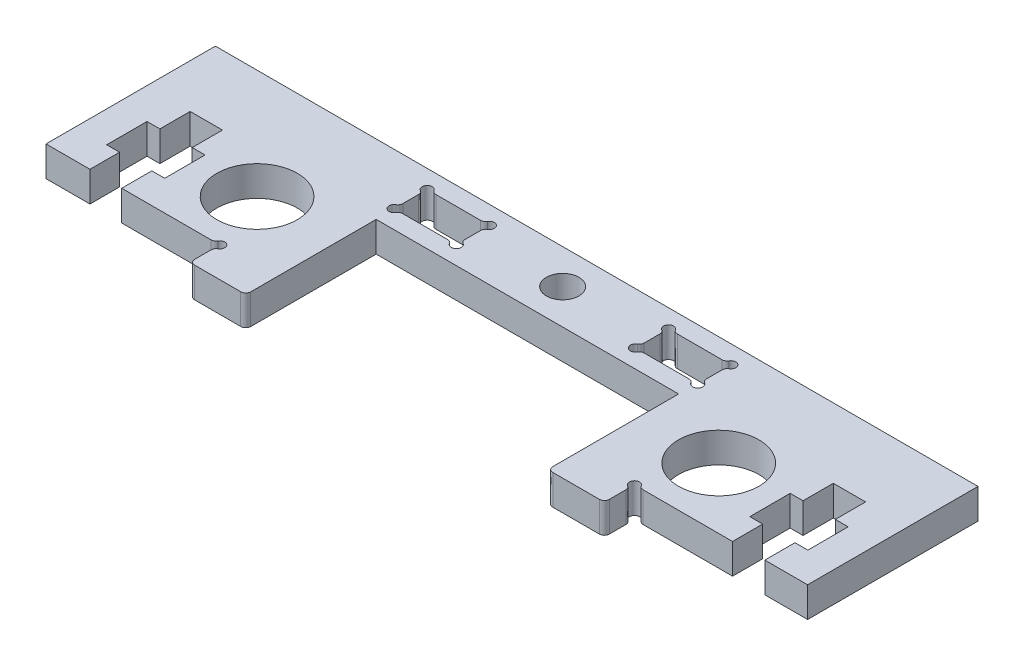
from build123d import *

# Parameters (mm, degrees)
SKETCH1_R           = 4.009255558
SKETCH1_R_2         = 1.619702369
BOSS_EXTRUDE1_DEPTH = 3


with BuildPart() as part:
    # Sketch1 → Boss-Extrude1 (new body)
    with BuildSketch(Plane(origin=(0, 0, 0), x_dir=(1, 0, 0), z_dir=(0, 1, 0))):
        with BuildLine():
            Line((-7.143850408, 18.229298667), (22.987065755, 18.229298667))
            Line((22.987065755, 18.229298667), (22.987065755, 7.324979297))
            Line((22.987065755, 7.324979297), (22.987065755, 5.690951323))
            ThreePointArc((22.987065755, 5.690951323), (23.133512364, 5.337397932), (23.487065755, 5.190951323))
            Line((23.487065755, 5.190951323), (28.129403654, 5.190951323))
            ThreePointArc((28.129403654, 5.190951323), (28.482956988, 5.337397909), (28.629403574, 5.690951243))
            Line((28.629403574, 5.690951243), (28.629403574, 7.324979243))
            ThreePointArc((28.629403574, 7.324979243), (28.56241665, 7.574978633), (28.379404865, 7.757991282))
            ThreePointArc((28.379404865, 7.757991282), (28.275853546, 8.544556775), (29.062418723, 8.441003056))
            ThreePointArc((29.062418723, 8.441003056), (29.245431425, 8.257990354), (29.495431425, 8.191003056))
            Line((29.495431425, 8.191003056), (38.401967533, 8.191003056))
            Line((38.401967533, 8.191003056), (38.401967533, 11.193716571))
            Line((38.401967533, 11.193716571), (37.120165143, 11.193716571))
            Line((37.120165143, 11.193716571), (37.120165143, 15.215104531))
            Line((37.120165143, 15.215104531), (38.40196755, 15.215104531))
            Line((38.40196755, 15.215104531), (38.40196755, 18.231124388))
            Line((38.40196755, 18.231124388), (41.619067462, 18.231124388))
            Line((41.619067462, 18.231124388), (41.619067462, 15.215104531))
            Line((41.619067462, 15.215104531), (42.900869869, 15.215104531))
            Line((42.900869869, 15.215104531), (42.900869869, 11.193716571))
            Line((42.900869869, 11.193716571), (41.619067445, 11.193716571))
            Line((41.619067445, 11.193716571), (41.619067445, 8.191003056))
            Line((41.619067445, 8.191003056), (45.879856116, 8.191003056))
            Line((45.879856116, 8.191003056), (45.879856116, 25.171092004))
            Line((45.879856116, 25.171092004), (-29.989227631, 25.171092004))
            ThreePointArc((-29.989227631, 25.171092004), (-30.077254418, 25.14100432), (-30.109006218, 25.053564013))
            Line((-30.109006218, 25.053564013), (-30.109006218, 8.29196371))
            Line((-30.109006218, 8.29196371), (-25.72867026, 8.29196371))
            Line((-25.72867026, 8.29196371), (-25.72867026, 11.238755399))
            Line((-25.72867026, 11.238755399), (-27.010472684, 11.238755399))
            Line((-27.010472684, 11.238755399), (-27.010472684, 15.260143358))
            Line((-27.010472684, 15.260143358), (-25.728670277, 15.260143358))
            Line((-25.728670277, 15.260143358), (-25.728670277, 18.276163216))
            Line((-25.728670277, 18.276163216), (-22.511570365, 18.276163216))
            Line((-22.511570365, 18.276163216), (-22.511570365, 15.260143358))
            Line((-22.511570365, 15.260143358), (-21.229767957, 15.260143358))
            Line((-21.229767957, 15.260143358), (-21.229767957, 11.238755399))
            Line((-21.229767957, 11.238755399), (-22.511570348, 11.238755399))
            Line((-22.511570348, 11.238755399), (-22.511570348, 8.236041884))
            Line((-22.511570348, 8.236041884), (-13.60503424, 8.236041884))
            ThreePointArc((-13.60503424, 8.236041884), (-13.356468602, 8.303656274), (-13.174549931, 8.486035491))
            ThreePointArc((-13.174549931, 8.486035491), (-12.387984754, 8.58958921), (-12.491536073, 7.803023717))
            ThreePointArc((-12.491536073, 7.803023717), (-12.674547858, 7.620011069), (-12.741534782, 7.370011678))
            Line((-12.741534782, 7.370011678), (-12.741534782, 5.735983678))
            ThreePointArc((-12.741534782, 5.735983678), (-12.595088173, 5.382430288), (-12.241534782, 5.235983678))
            Line((-12.241534782, 5.235983678), (-7.653939136, 5.235983678))
            ThreePointArc((-7.653939136, 5.235983678), (-7.309014548, 5.362697937), (-7.143850408, 5.690951317))
            Line((-7.143850408, 5.690951317), (-7.143850408, 7.324979297))
            Line((-7.143850408, 7.324979297), (-7.143850408, 18.229298667))
        make_face()
        with Locations((-15.055624081, 14.270241393)):
            Circle(SKETCH1_R, mode=Mode.SUBTRACT)
        with Locations((30.946299637, 14.270241393)):
            Circle(SKETCH1_R, mode=Mode.SUBTRACT)
        with BuildLine():
            ThreePointArc((-6.750210098, 23.598159475), (-6.567197449, 23.415147689), (-6.317198059, 23.348160765))
            Line((-6.317198059, 23.348160765), (-1.849249059, 23.348160765))
            ThreePointArc((-1.849249059, 23.348160765), (-1.599248991, 23.415148256), (-1.41623632, 23.598161152))
            ThreePointArc((-1.41623632, 23.598161152), (-0.629670838, 23.701715154), (-0.733222121, 22.915149315))
            ThreePointArc((-0.733222121, 22.915149315), (-0.916234557, 22.73213507), (-0.983220424, 22.482133752))
            Line((-0.983220424, 22.482133752), (-0.983220424, 20.914266752))
            ThreePointArc((-0.983220424, 20.914266752), (-0.916233017, 20.664266494), (-0.733220037, 20.481253678))
            ThreePointArc((-0.733220037, 20.481253678), (-0.629666036, 19.694688196), (-1.416231875, 19.798239479))
            ThreePointArc((-1.416231875, 19.798239479), (-1.599244524, 19.981251265), (-1.849243914, 20.048238189))
            Line((-1.849243914, 20.048238189), (-6.317193914, 20.048238189))
            ThreePointArc((-6.317193914, 20.048238189), (-6.567193914, 19.981250891), (-6.750206616, 19.798238189))
            ThreePointArc((-6.750206616, 19.798238189), (-7.536772071, 19.694684496), (-7.433220534, 20.481250235))
            ThreePointArc((-7.433220534, 20.481250235), (-7.250208657, 20.664263235), (-7.18322203, 20.91426303))
            Line((-7.18322203, 20.91426303), (-7.18322203, 22.48213303))
            ThreePointArc((-7.18322203, 22.48213303), (-7.250209567, 22.732132487), (-7.43322203, 22.915144775))
            ThreePointArc((-7.43322203, 22.915144775), (-7.536776448, 23.701710706), (-6.750210098, 23.598159475))
        make_face(mode=Mode.SUBTRACT)
        with Locations((7.945337781, 21.71531407)):
            Circle(SKETCH1_R_2, mode=Mode.SUBTRACT)
        with BuildLine():
            Line((17.739921148, 23.348159476), (22.207870148, 23.348159476))
            ThreePointArc((22.207870148, 23.348159476), (22.457869729, 23.415146316), (22.640882523, 23.598158186))
            ThreePointArc((22.640882523, 23.598158186), (23.427448874, 23.701709417), (23.323894455, 22.915143486))
            ThreePointArc((23.323894455, 22.915143486), (23.140882484, 22.732132355), (23.073894191, 22.482134307))
            Line((23.073894191, 22.482134307), (23.073894191, 20.914264307))
            ThreePointArc((23.073894191, 20.914264307), (23.140881057, 20.664265055), (23.323892694, 20.481252469))
            ThreePointArc((23.323892694, 20.481252469), (23.427444232, 19.69468673), (22.640878777, 19.798240423))
            ThreePointArc((22.640878777, 19.798240423), (22.457866075, 19.981253125), (22.207866075, 20.048240423))
            Line((22.207866075, 20.048240423), (17.739916075, 20.048240423))
            ThreePointArc((17.739916075, 20.048240423), (17.489916684, 19.981253499), (17.306904036, 19.798241714))
            ThreePointArc((17.306904036, 19.798241714), (16.520338196, 19.69469043), (16.623892198, 20.481255912))
            ThreePointArc((16.623892198, 20.481255912), (16.806904939, 20.664268314), (16.873892585, 20.91426803))
            Line((16.873892585, 20.91426803), (16.873892585, 22.48213503))
            ThreePointArc((16.873892585, 22.48213503), (16.8069059, 22.732134962), (16.623893876, 22.915148025))
            ThreePointArc((16.623893876, 22.915148025), (16.520342592, 23.701713865), (17.306908074, 23.598159863))
            ThreePointArc((17.306908074, 23.598159863), (17.48992089, 23.415146883), (17.739921148, 23.348159476))
        make_face(mode=Mode.SUBTRACT)
    extrude(amount=BOSS_EXTRUDE1_DEPTH)


solid = part.part
